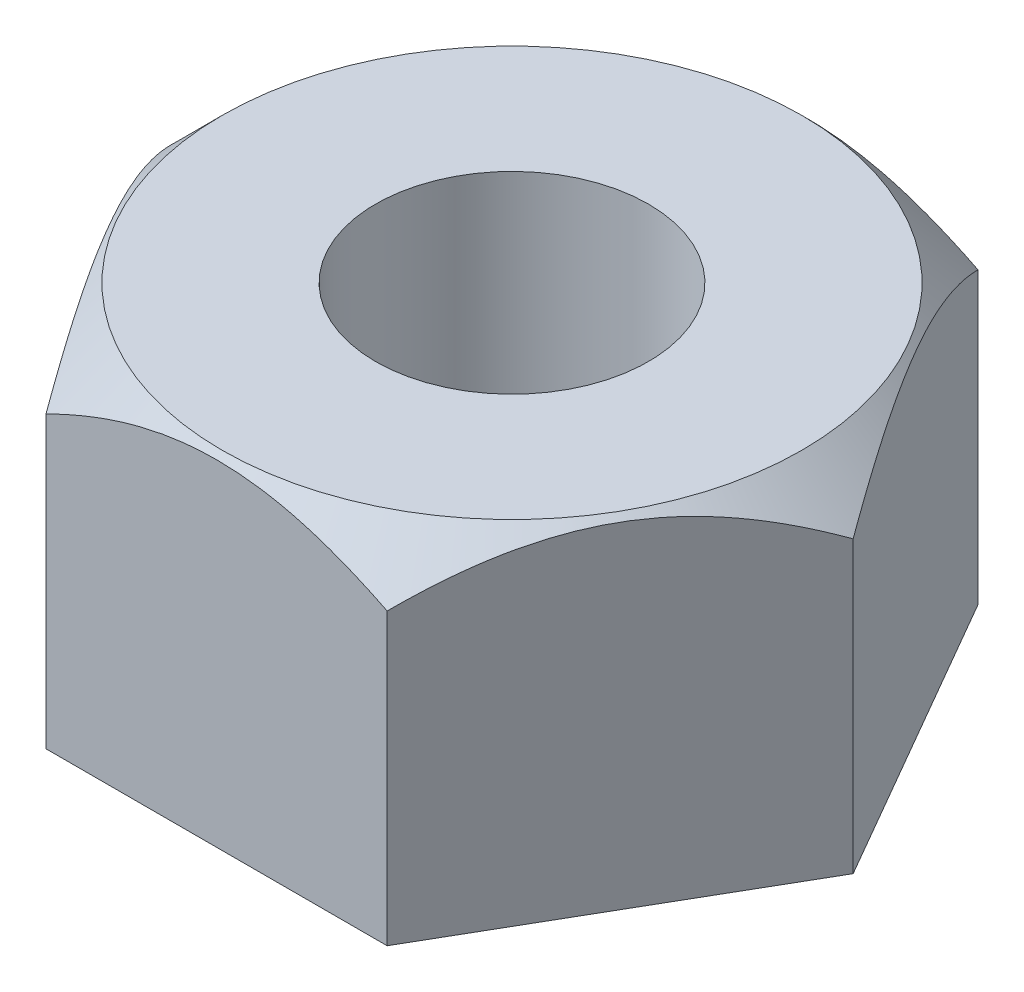
from build123d import *

# Parameters (mm, degrees)
SKETCH1_R           = 2
BOSS_EXTRUDE1_DEPTH = 5
SKETCH2_OUTSIDE_W   = 24.828
SKETCH2_OUTSIDE_H   = 23.488
SKETCH2_OUTSIDE_R   = 4.25
CUT_EXTRUDE1_DEPTH  = 5
CUT_EXTRUDE1_TAPER  = 45


with BuildPart() as part:
    # Sketch1 → Boss-Extrude1 (new body)
    with BuildSketch(Plane(origin=(0, 0, 0), x_dir=(1, 0, 0), z_dir=(0, 1, 0))):
        Polygon((5, 0), (2.5, 4.330127019), (-2.5, 4.330127019), (-5, 0), (-2.5, -4.330127019), (2.5, -4.330127019), align=None)
        Circle(SKETCH1_R, mode=Mode.SUBTRACT)
    extrude(amount=BOSS_EXTRUDE1_DEPTH)

    # Sketch2 outside → Cut-Extrude1 (cut)
    with BuildSketch(Plane(origin=(0, 5, 0), x_dir=(1, 0, 0), z_dir=(0, 1, 0))):
        Rectangle(SKETCH2_OUTSIDE_W, SKETCH2_OUTSIDE_H)
        Circle(SKETCH2_OUTSIDE_R, mode=Mode.SUBTRACT)
    extrude(amount=-CUT_EXTRUDE1_DEPTH, taper=CUT_EXTRUDE1_TAPER, mode=Mode.SUBTRACT)


solid = part.part
